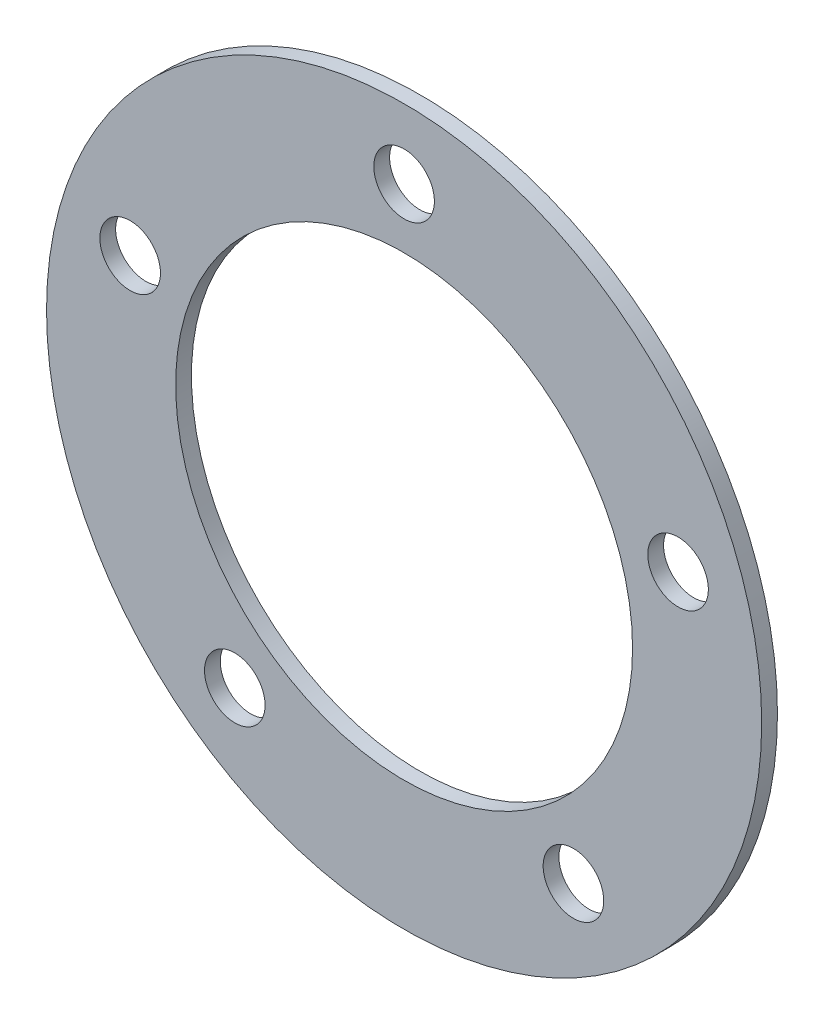
from build123d import *

# Parameters (mm, degrees)
SKETCH1_R           = 18
SKETCH1_R_2         = 11.5
SKETCH1_R_3         = 1.525
BOSS_EXTRUDE1_DEPTH = 0.79375


with BuildPart() as part:
    # Sketch1 → Boss-Extrude1 (new body)
    with BuildSketch(Plane.XY):
        Circle(SKETCH1_R)
        Circle(SKETCH1_R_2, mode=Mode.SUBTRACT)
        with Locations((0, 14.5)):
            Circle(SKETCH1_R_3, mode=Mode.SUBTRACT)
        with Locations((13.790319486, 4.480746418)):
            Circle(SKETCH1_R_3, mode=Mode.SUBTRACT)
        with Locations((8.522886158, -11.730746418)):
            Circle(SKETCH1_R_3, mode=Mode.SUBTRACT)
        with Locations((-8.522886158, -11.730746418)):
            Circle(SKETCH1_R_3, mode=Mode.SUBTRACT)
        with Locations((-13.790319486, 4.480746418)):
            Circle(SKETCH1_R_3, mode=Mode.SUBTRACT)
    extrude(amount=BOSS_EXTRUDE1_DEPTH)


solid = part.part
